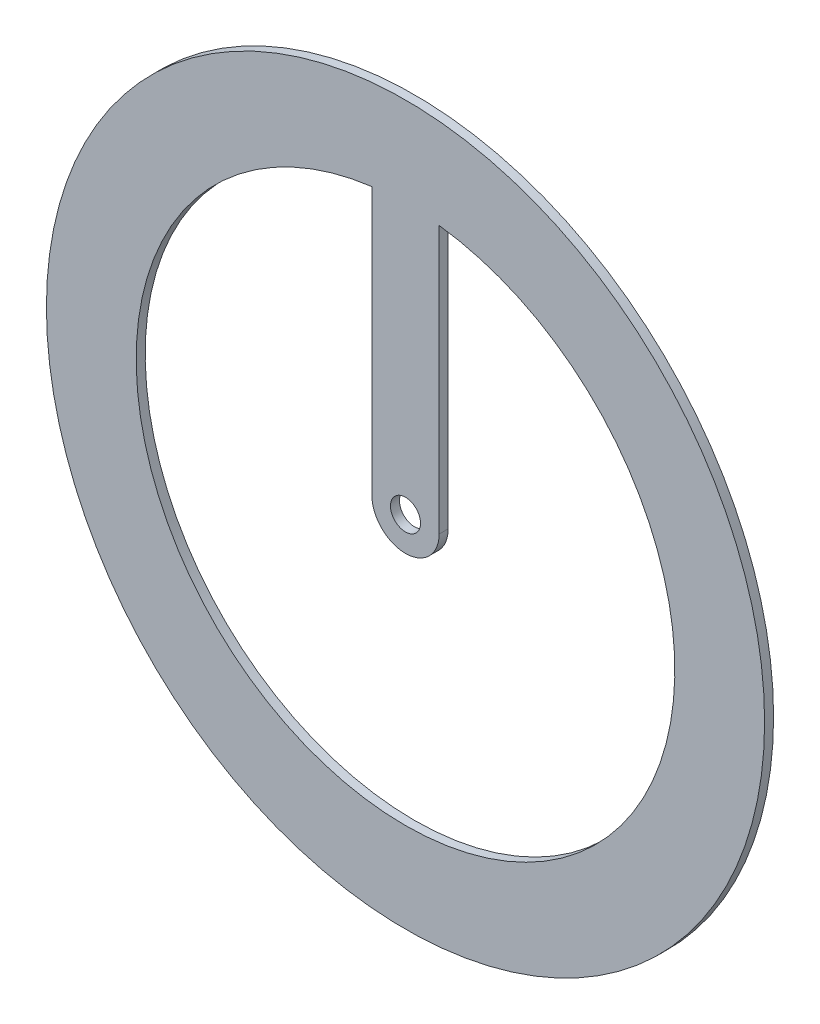
from build123d import *

# Parameters (mm, degrees)
SKETCH1_R           = 101.6
SKETCH1_R_2         = 4.24957387
BOSS_EXTRUDE1_DEPTH = 2.54


with BuildPart() as part:
    # Sketch1 → Boss-Extrude1 (new body)
    with BuildSketch(Plane.XY):
        Circle(SKETCH1_R)
        Circle(SKETCH1_R_2, mode=Mode.SUBTRACT)
        with BuildLine():
            Line((-9.525, 0), (-9.525, 75.602343714))
            ThreePointArc((-9.525, 75.602343714), (0, -76.2), (9.525, 75.602343714))
            Line((9.525, 75.602343714), (9.525, 0))
            ThreePointArc((9.525, 0), (0, -9.525), (-9.525, 0))
        make_face(mode=Mode.SUBTRACT)
    extrude(amount=BOSS_EXTRUDE1_DEPTH)


solid = part.part
